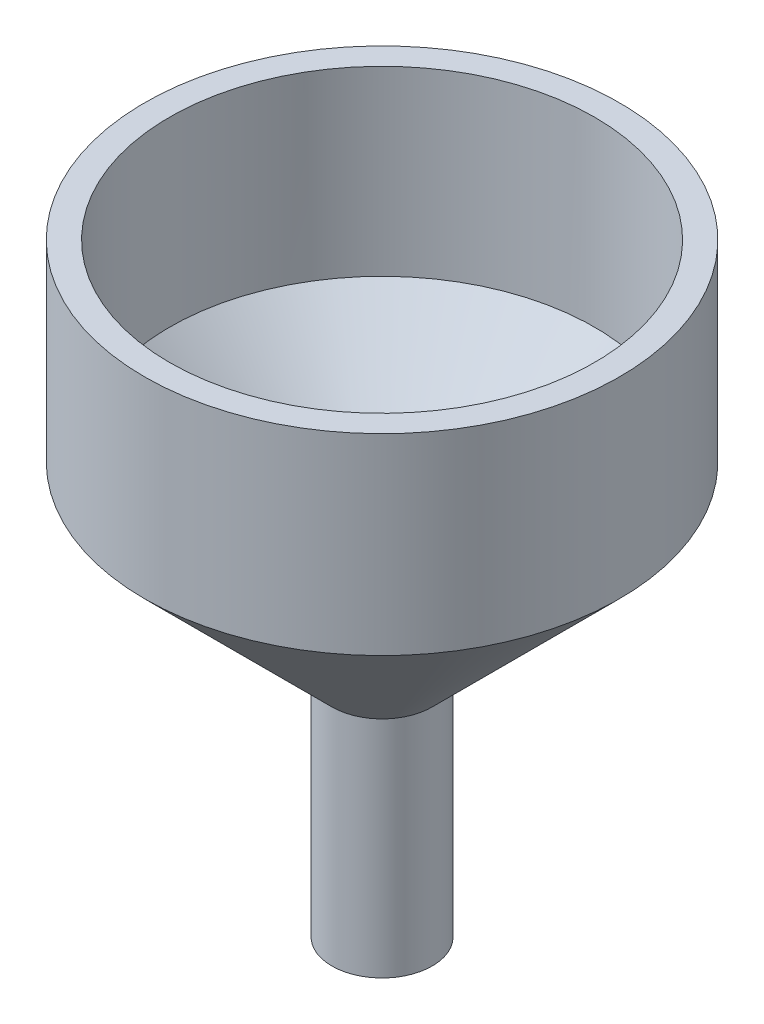
from build123d import *

# Parameters (mm, degrees)
VACIADO1_T = -5


with BuildPart() as part:
    # Croquis1 → Revolución1 (revolve)
    with BuildSketch(Plane(origin=(0, 0, 0), x_dir=(0, 0, -1), z_dir=(1, 0, 0)), mode=Mode.PRIVATE) as revoluci_n1_sk:
        Polygon((0, 53.716293677), (0, -67.370540613), (10.067532341, -67.370540613), (10.067532341, -22.376525686), (47.617684505, 15.173626478), (47.617684505, 53.716293677), align=None)
    revolve(revoluci_n1_sk.sketch.rotate(Axis((0, 53.716293677, 0), (0, -1, 0)), 180), axis=Axis((0, 53.716293677, 0), (0, -1, 0)))

    # Vaciado1
    vaciado1_openings = [part.faces().sort_by_distance(p)[0] for p in [
        (0, -67.370540613, 0),
        (0, 53.716293677, 0),
    ]]
    offset(amount=VACIADO1_T, openings=vaciado1_openings, kind=Kind.INTERSECTION)


solid = part.part
